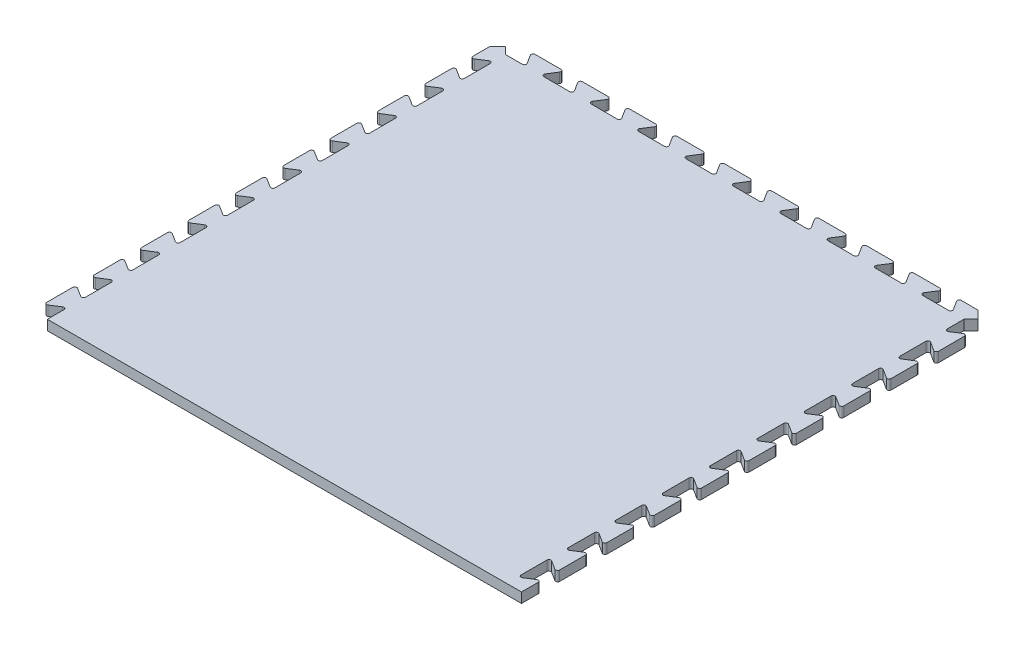
from build123d import *

# Parameters (mm, degrees)
BOSS_EXTRUDE1_DEPTH = 12.7


with BuildPart() as part:
    # Sketch1 → Boss-Extrude1 (new body)
    with BuildSketch(Plane.XZ):
        with BuildLine():
            Line((310.941368192, 290.73579192), (-291.891368192, 291.891368192))
            Line((-291.891368192, 291.891368192), (-291.891368192, 270.60420808))
            ThreePointArc((-291.891368192, 270.60420808), (-293.208312471, 268.378060129), (-295.793521501, 268.460347459))
            Line((-295.793521501, 268.460347459), (-307.039214883, 275.605568702))
            ThreePointArc((-307.039214883, 275.605568702), (-309.624423913, 275.687856032), (-310.941368192, 273.46170808))
            Line((-310.941368192, 273.46170808), (-310.941368192, 240.44170808))
            ThreePointArc((-310.941368192, 240.44170808), (-309.624423913, 238.215560129), (-307.039214883, 238.297847459))
            Line((-307.039214883, 238.297847459), (-295.793521501, 245.443068702))
            ThreePointArc((-295.793521501, 245.443068702), (-293.208312471, 245.525356032), (-291.891368192, 243.29920808))
            Line((-291.891368192, 243.29920808), (-291.891368192, 210.27920808))
            ThreePointArc((-291.891368192, 210.27920808), (-293.208312471, 208.053060129), (-295.793521501, 208.135347459))
            Line((-295.793521501, 208.135347459), (-307.039214883, 215.280568702))
            ThreePointArc((-307.039214883, 215.280568702), (-309.624423913, 215.362856032), (-310.941368192, 213.13670808))
            Line((-310.941368192, 213.13670808), (-310.941368192, 180.11670808))
            ThreePointArc((-310.941368192, 180.11670808), (-309.624423913, 177.890560129), (-307.039214883, 177.972847459))
            Line((-307.039214883, 177.972847459), (-295.793521501, 185.118068702))
            ThreePointArc((-295.793521501, 185.118068702), (-293.208312471, 185.200356032), (-291.891368192, 182.97420808))
            Line((-291.891368192, 182.97420808), (-291.891368192, 149.95420808))
            ThreePointArc((-291.891368192, 149.95420808), (-293.208312471, 147.728060129), (-295.793521501, 147.810347459))
            Line((-295.793521501, 147.810347459), (-307.039214883, 154.955568702))
            ThreePointArc((-307.039214883, 154.955568702), (-309.624423913, 155.037856032), (-310.941368192, 152.81170808))
            Line((-310.941368192, 152.81170808), (-310.941368192, 119.79170808))
            ThreePointArc((-310.941368192, 119.79170808), (-309.624423913, 117.565560129), (-307.039214883, 117.647847459))
            Line((-307.039214883, 117.647847459), (-295.793521501, 124.793068702))
            ThreePointArc((-295.793521501, 124.793068702), (-293.208312471, 124.875356032), (-291.891368192, 122.64920808))
            Line((-291.891368192, 122.64920808), (-291.891368192, 89.62920808))
            ThreePointArc((-291.891368192, 89.62920808), (-293.208312471, 87.403060129), (-295.793521501, 87.485347459))
            Line((-295.793521501, 87.485347459), (-307.039214883, 94.630568702))
            ThreePointArc((-307.039214883, 94.630568702), (-309.624423913, 94.712856032), (-310.941368192, 92.48670808))
            Line((-310.941368192, 92.48670808), (-310.941368192, 59.46670808))
            ThreePointArc((-310.941368192, 59.46670808), (-309.624423913, 57.240560129), (-307.039214883, 57.322847459))
            Line((-307.039214883, 57.322847459), (-295.793521501, 64.468068702))
            ThreePointArc((-295.793521501, 64.468068702), (-293.208312471, 64.550356032), (-291.891368192, 62.32420808))
            Line((-291.891368192, 62.32420808), (-291.891368192, 29.30420808))
            ThreePointArc((-291.891368192, 29.30420808), (-293.208312471, 27.078060129), (-295.793521501, 27.160347459))
            Line((-295.793521501, 27.160347459), (-307.039214883, 34.305568702))
            ThreePointArc((-307.039214883, 34.305568702), (-309.624423913, 34.387856032), (-310.941368192, 32.16170808))
            Line((-310.941368192, 32.16170808), (-310.941368192, -0.85829192))
            ThreePointArc((-310.941368192, -0.85829192), (-309.624423913, -3.084439871), (-307.039214883, -3.002152541))
            Line((-307.039214883, -3.002152541), (-295.793521501, 4.143068702))
            ThreePointArc((-295.793521501, 4.143068702), (-293.208312471, 4.225356032), (-291.891368192, 1.99920808))
            Line((-291.891368192, 1.99920808), (-291.891368192, -31.02079192))
            ThreePointArc((-291.891368192, -31.02079192), (-293.208312471, -33.246939871), (-295.793521501, -33.164652541))
            Line((-295.793521501, -33.164652541), (-307.039214883, -26.019431298))
            ThreePointArc((-307.039214883, -26.019431298), (-309.624423913, -25.937143968), (-310.941368192, -28.16329192))
            Line((-310.941368192, -28.16329192), (-310.941368192, -61.18329192))
            ThreePointArc((-310.941368192, -61.18329192), (-309.624423913, -63.409439871), (-307.039214883, -63.327152541))
            Line((-307.039214883, -63.327152541), (-295.793521501, -56.181931298))
            ThreePointArc((-295.793521501, -56.181931298), (-293.208312471, -56.099643968), (-291.891368192, -58.32579192))
            Line((-291.891368192, -58.32579192), (-291.891368192, -91.34579192))
            ThreePointArc((-291.891368192, -91.34579192), (-293.208312471, -93.571939871), (-295.793521501, -93.489652541))
            Line((-295.793521501, -93.489652541), (-307.039214883, -86.344431298))
            ThreePointArc((-307.039214883, -86.344431298), (-309.624423913, -86.262143968), (-310.941368192, -88.48829192))
            Line((-310.941368192, -88.48829192), (-310.941368192, -121.50829192))
            ThreePointArc((-310.941368192, -121.50829192), (-309.624423913, -123.734439871), (-307.039214883, -123.652152541))
            Line((-307.039214883, -123.652152541), (-295.793521501, -116.506931298))
            ThreePointArc((-295.793521501, -116.506931298), (-293.208312471, -116.424643968), (-291.891368192, -118.65079192))
            Line((-291.891368192, -118.65079192), (-291.891368192, -151.67079192))
            ThreePointArc((-291.891368192, -151.67079192), (-293.208312471, -153.896939871), (-295.793521501, -153.814652541))
            Line((-295.793521501, -153.814652541), (-307.039214883, -146.669431298))
            ThreePointArc((-307.039214883, -146.669431298), (-309.624423913, -146.587143968), (-310.941368192, -148.81329192))
            Line((-310.941368192, -148.81329192), (-310.941368192, -181.83329192))
            ThreePointArc((-310.941368192, -181.83329192), (-309.624423913, -184.059439871), (-307.039214883, -183.977152541))
            Line((-307.039214883, -183.977152541), (-295.793521501, -176.831931298))
            ThreePointArc((-295.793521501, -176.831931298), (-293.208312471, -176.749643968), (-291.891368192, -178.97579192))
            Line((-291.891368192, -178.97579192), (-291.891368192, -211.99579192))
            ThreePointArc((-291.891368192, -211.99579192), (-293.208312471, -214.221939871), (-295.793521501, -214.139652541))
            Line((-295.793521501, -214.139652541), (-307.039214883, -206.994431298))
            ThreePointArc((-307.039214883, -206.994431298), (-309.624423913, -206.912143968), (-310.941368192, -209.13829192))
            Line((-310.941368192, -209.13829192), (-310.941368192, -242.15829192))
            ThreePointArc((-310.941368192, -242.15829192), (-309.624423913, -244.384439871), (-307.039214883, -244.302152541))
            Line((-307.039214883, -244.302152541), (-295.793521501, -237.156931298))
            ThreePointArc((-295.793521501, -237.156931298), (-293.208312471, -237.074643968), (-291.891368192, -239.30079192))
            Line((-291.891368192, -239.30079192), (-291.891368192, -272.32079192))
            ThreePointArc((-291.891368192, -272.32079192), (-293.208312471, -274.546939871), (-295.793521501, -274.464652541))
            Line((-295.793521501, -274.464652541), (-307.039214883, -267.319431298))
            ThreePointArc((-307.039214883, -267.319431298), (-309.624423913, -267.237143968), (-310.941368192, -269.46329192))
            Line((-310.941368192, -269.46329192), (-310.941368192, -290.73579192))
            Line((-310.941368192, -290.73579192), (-300.838580056, -300.838580056))
            Line((-300.838580056, -300.838580056), (-291.891368192, -291.891368192))
            Line((-291.891368192, -291.891368192), (-270.60420808, -291.891368192))
            ThreePointArc((-270.60420808, -291.891368192), (-268.378060129, -293.208312471), (-268.460347459, -295.793521501))
            Line((-268.460347459, -295.793521501), (-275.605568702, -307.039214883))
            ThreePointArc((-275.605568702, -307.039214883), (-275.687856032, -309.624423913), (-273.46170808, -310.941368192))
            Line((-273.46170808, -310.941368192), (-240.44170808, -310.941368192))
            ThreePointArc((-240.44170808, -310.941368192), (-238.215560129, -309.624423913), (-238.297847459, -307.039214883))
            Line((-238.297847459, -307.039214883), (-245.443068702, -295.793521501))
            ThreePointArc((-245.443068702, -295.793521501), (-245.525356032, -293.208312471), (-243.29920808, -291.891368192))
            Line((-243.29920808, -291.891368192), (-210.27920808, -291.891368192))
            ThreePointArc((-210.27920808, -291.891368192), (-208.053060129, -293.208312471), (-208.135347459, -295.793521501))
            Line((-208.135347459, -295.793521501), (-215.280568702, -307.039214883))
            ThreePointArc((-215.280568702, -307.039214883), (-215.362856032, -309.624423913), (-213.13670808, -310.941368192))
            Line((-213.13670808, -310.941368192), (-180.11670808, -310.941368192))
            ThreePointArc((-180.11670808, -310.941368192), (-177.890560129, -309.624423913), (-177.972847459, -307.039214883))
            Line((-177.972847459, -307.039214883), (-185.118068702, -295.793521501))
            ThreePointArc((-185.118068702, -295.793521501), (-185.200356032, -293.208312471), (-182.97420808, -291.891368192))
            Line((-182.97420808, -291.891368192), (-149.95420808, -291.891368192))
            ThreePointArc((-149.95420808, -291.891368192), (-147.728060129, -293.208312471), (-147.810347459, -295.793521501))
            Line((-147.810347459, -295.793521501), (-154.955568702, -307.039214883))
            ThreePointArc((-154.955568702, -307.039214883), (-155.037856032, -309.624423913), (-152.81170808, -310.941368192))
            Line((-152.81170808, -310.941368192), (-119.79170808, -310.941368192))
            ThreePointArc((-119.79170808, -310.941368192), (-117.565560129, -309.624423913), (-117.647847459, -307.039214883))
            Line((-117.647847459, -307.039214883), (-124.793068702, -295.793521501))
            ThreePointArc((-124.793068702, -295.793521501), (-124.875356032, -293.208312471), (-122.64920808, -291.891368192))
            Line((-122.64920808, -291.891368192), (-89.62920808, -291.891368192))
            ThreePointArc((-89.62920808, -291.891368192), (-87.403060129, -293.208312471), (-87.485347459, -295.793521501))
            Line((-87.485347459, -295.793521501), (-94.630568702, -307.039214883))
            ThreePointArc((-94.630568702, -307.039214883), (-94.712856032, -309.624423913), (-92.48670808, -310.941368192))
            Line((-92.48670808, -310.941368192), (-59.46670808, -310.941368192))
            ThreePointArc((-59.46670808, -310.941368192), (-57.240560129, -309.624423913), (-57.322847459, -307.039214883))
            Line((-57.322847459, -307.039214883), (-64.468068702, -295.793521501))
            ThreePointArc((-64.468068702, -295.793521501), (-64.550356032, -293.208312471), (-62.32420808, -291.891368192))
            Line((-62.32420808, -291.891368192), (-29.30420808, -291.891368192))
            ThreePointArc((-29.30420808, -291.891368192), (-27.078060129, -293.208312471), (-27.160347459, -295.793521501))
            Line((-27.160347459, -295.793521501), (-34.305568702, -307.039214883))
            ThreePointArc((-34.305568702, -307.039214883), (-34.387856032, -309.624423913), (-32.16170808, -310.941368192))
            Line((-32.16170808, -310.941368192), (0.85829192, -310.941368192))
            ThreePointArc((0.85829192, -310.941368192), (3.084439871, -309.624423913), (3.002152541, -307.039214883))
            Line((3.002152541, -307.039214883), (-4.143068702, -295.793521501))
            ThreePointArc((-4.143068702, -295.793521501), (-4.225356032, -293.208312471), (-1.99920808, -291.891368192))
            Line((-1.99920808, -291.891368192), (31.02079192, -291.891368192))
            ThreePointArc((31.02079192, -291.891368192), (33.246939871, -293.208312471), (33.164652541, -295.793521501))
            Line((33.164652541, -295.793521501), (26.019431298, -307.039214883))
            ThreePointArc((26.019431298, -307.039214883), (25.937143968, -309.624423913), (28.16329192, -310.941368192))
            Line((28.16329192, -310.941368192), (61.18329192, -310.941368192))
            ThreePointArc((61.18329192, -310.941368192), (63.409439871, -309.624423913), (63.327152541, -307.039214883))
            Line((63.327152541, -307.039214883), (56.181931298, -295.793521501))
            ThreePointArc((56.181931298, -295.793521501), (56.099643968, -293.208312471), (58.32579192, -291.891368192))
            Line((58.32579192, -291.891368192), (91.34579192, -291.891368192))
            ThreePointArc((91.34579192, -291.891368192), (93.571939871, -293.208312471), (93.489652541, -295.793521501))
            Line((93.489652541, -295.793521501), (86.344431298, -307.039214883))
            ThreePointArc((86.344431298, -307.039214883), (86.262143968, -309.624423913), (88.48829192, -310.941368192))
            Line((88.48829192, -310.941368192), (121.50829192, -310.941368192))
            ThreePointArc((121.50829192, -310.941368192), (123.734439871, -309.624423913), (123.652152541, -307.039214883))
            Line((123.652152541, -307.039214883), (116.506931298, -295.793521501))
            ThreePointArc((116.506931298, -295.793521501), (116.424643968, -293.208312471), (118.65079192, -291.891368192))
            Line((118.65079192, -291.891368192), (151.67079192, -291.891368192))
            ThreePointArc((151.67079192, -291.891368192), (153.896939871, -293.208312471), (153.814652541, -295.793521501))
            Line((153.814652541, -295.793521501), (146.669431298, -307.039214883))
            ThreePointArc((146.669431298, -307.039214883), (146.587143968, -309.624423913), (148.81329192, -310.941368192))
            Line((148.81329192, -310.941368192), (181.83329192, -310.941368192))
            ThreePointArc((181.83329192, -310.941368192), (184.059439871, -309.624423913), (183.977152541, -307.039214883))
            Line((183.977152541, -307.039214883), (176.831931298, -295.793521501))
            ThreePointArc((176.831931298, -295.793521501), (176.749643968, -293.208312471), (178.97579192, -291.891368192))
            Line((178.97579192, -291.891368192), (211.99579192, -291.891368192))
            ThreePointArc((211.99579192, -291.891368192), (214.221939871, -293.208312471), (214.139652541, -295.793521501))
            Line((214.139652541, -295.793521501), (206.994431298, -307.039214883))
            ThreePointArc((206.994431298, -307.039214883), (206.912143968, -309.624423913), (209.13829192, -310.941368192))
            Line((209.13829192, -310.941368192), (242.15829192, -310.941368192))
            ThreePointArc((242.15829192, -310.941368192), (244.384439871, -309.624423913), (244.302152541, -307.039214883))
            Line((244.302152541, -307.039214883), (237.156931298, -295.793521501))
            ThreePointArc((237.156931298, -295.793521501), (237.074643968, -293.208312471), (239.30079192, -291.891368192))
            Line((239.30079192, -291.891368192), (272.32079192, -291.891368192))
            ThreePointArc((272.32079192, -291.891368192), (274.546939871, -293.208312471), (274.464652541, -295.793521501))
            Line((274.464652541, -295.793521501), (267.319431298, -307.039214883))
            ThreePointArc((267.319431298, -307.039214883), (267.237143968, -309.624423913), (269.46329192, -310.941368192))
            Line((269.46329192, -310.941368192), (290.73579192, -310.941368192))
            Line((290.73579192, -310.941368192), (300.838580056, -300.838580056))
            Line((300.838580056, -300.838580056), (291.891368192, -291.891368192))
            Line((291.891368192, -291.891368192), (291.891368192, -270.60420808))
            ThreePointArc((291.891368192, -270.60420808), (293.208312471, -268.378060129), (295.793521501, -268.460347459))
            Line((295.793521501, -268.460347459), (307.039214883, -275.605568702))
            ThreePointArc((307.039214883, -275.605568702), (309.624423913, -275.687856032), (310.941368192, -273.46170808))
            Line((310.941368192, -273.46170808), (310.941368192, -240.44170808))
            ThreePointArc((310.941368192, -240.44170808), (309.624423913, -238.215560129), (307.039214883, -238.297847459))
            Line((307.039214883, -238.297847459), (295.793521501, -245.443068702))
            ThreePointArc((295.793521501, -245.443068702), (293.208312471, -245.525356032), (291.891368192, -243.29920808))
            Line((291.891368192, -243.29920808), (291.891368192, -210.27920808))
            ThreePointArc((291.891368192, -210.27920808), (293.208312471, -208.053060129), (295.793521501, -208.135347459))
            Line((295.793521501, -208.135347459), (307.039214883, -215.280568702))
            ThreePointArc((307.039214883, -215.280568702), (309.624423913, -215.362856032), (310.941368192, -213.13670808))
            Line((310.941368192, -213.13670808), (310.941368192, -180.11670808))
            ThreePointArc((310.941368192, -180.11670808), (309.624423913, -177.890560129), (307.039214883, -177.972847459))
            Line((307.039214883, -177.972847459), (295.793521501, -185.118068702))
            ThreePointArc((295.793521501, -185.118068702), (293.208312471, -185.200356032), (291.891368192, -182.97420808))
            Line((291.891368192, -182.97420808), (291.891368192, -149.95420808))
            ThreePointArc((291.891368192, -149.95420808), (293.208312471, -147.728060129), (295.793521501, -147.810347459))
            Line((295.793521501, -147.810347459), (307.039214883, -154.955568702))
            ThreePointArc((307.039214883, -154.955568702), (309.624423913, -155.037856032), (310.941368192, -152.81170808))
            Line((310.941368192, -152.81170808), (310.941368192, -119.79170808))
            ThreePointArc((310.941368192, -119.79170808), (309.624423913, -117.565560129), (307.039214883, -117.647847459))
            Line((307.039214883, -117.647847459), (295.793521501, -124.793068702))
            ThreePointArc((295.793521501, -124.793068702), (293.208312471, -124.875356032), (291.891368192, -122.64920808))
            Line((291.891368192, -122.64920808), (291.891368192, -89.62920808))
            ThreePointArc((291.891368192, -89.62920808), (293.208312471, -87.403060129), (295.793521501, -87.485347459))
            Line((295.793521501, -87.485347459), (307.039214883, -94.630568702))
            ThreePointArc((307.039214883, -94.630568702), (309.624423913, -94.712856032), (310.941368192, -92.48670808))
            Line((310.941368192, -92.48670808), (310.941368192, -59.46670808))
            ThreePointArc((310.941368192, -59.46670808), (309.624423913, -57.240560129), (307.039214883, -57.322847459))
            Line((307.039214883, -57.322847459), (295.793521501, -64.468068702))
            ThreePointArc((295.793521501, -64.468068702), (293.208312471, -64.550356032), (291.891368192, -62.32420808))
            Line((291.891368192, -62.32420808), (291.891368192, -29.30420808))
            ThreePointArc((291.891368192, -29.30420808), (293.208312471, -27.078060129), (295.793521501, -27.160347459))
            Line((295.793521501, -27.160347459), (307.039214883, -34.305568702))
            ThreePointArc((307.039214883, -34.305568702), (309.624423913, -34.387856032), (310.941368192, -32.16170808))
            Line((310.941368192, -32.16170808), (310.941368192, 0.85829192))
            ThreePointArc((310.941368192, 0.85829192), (309.624423913, 3.084439871), (307.039214883, 3.002152541))
            Line((307.039214883, 3.002152541), (295.793521501, -4.143068702))
            ThreePointArc((295.793521501, -4.143068702), (293.208312471, -4.225356032), (291.891368192, -1.99920808))
            Line((291.891368192, -1.99920808), (291.891368192, 31.02079192))
            ThreePointArc((291.891368192, 31.02079192), (293.208312471, 33.246939871), (295.793521501, 33.164652541))
            Line((295.793521501, 33.164652541), (307.039214883, 26.019431298))
            ThreePointArc((307.039214883, 26.019431298), (309.624423913, 25.937143968), (310.941368192, 28.16329192))
            Line((310.941368192, 28.16329192), (310.941368192, 61.18329192))
            ThreePointArc((310.941368192, 61.18329192), (309.624423913, 63.409439871), (307.039214883, 63.327152541))
            Line((307.039214883, 63.327152541), (295.793521501, 56.181931298))
            ThreePointArc((295.793521501, 56.181931298), (293.208312471, 56.099643968), (291.891368192, 58.32579192))
            Line((291.891368192, 58.32579192), (291.891368192, 91.34579192))
            ThreePointArc((291.891368192, 91.34579192), (293.208312471, 93.571939871), (295.793521501, 93.489652541))
            Line((295.793521501, 93.489652541), (307.039214883, 86.344431298))
            ThreePointArc((307.039214883, 86.344431298), (309.624423913, 86.262143968), (310.941368192, 88.48829192))
            Line((310.941368192, 88.48829192), (310.941368192, 121.50829192))
            ThreePointArc((310.941368192, 121.50829192), (309.624423913, 123.734439871), (307.039214883, 123.652152541))
            Line((307.039214883, 123.652152541), (295.793521501, 116.506931298))
            ThreePointArc((295.793521501, 116.506931298), (293.208312471, 116.424643968), (291.891368192, 118.65079192))
            Line((291.891368192, 118.65079192), (291.891368192, 151.67079192))
            ThreePointArc((291.891368192, 151.67079192), (293.208312471, 153.896939871), (295.793521501, 153.814652541))
            Line((295.793521501, 153.814652541), (307.039214883, 146.669431298))
            ThreePointArc((307.039214883, 146.669431298), (309.624423913, 146.587143968), (310.941368192, 148.81329192))
            Line((310.941368192, 148.81329192), (310.941368192, 181.83329192))
            ThreePointArc((310.941368192, 181.83329192), (309.624423913, 184.059439871), (307.039214883, 183.977152541))
            Line((307.039214883, 183.977152541), (295.793521501, 176.831931298))
            ThreePointArc((295.793521501, 176.831931298), (293.208312471, 176.749643968), (291.891368192, 178.97579192))
            Line((291.891368192, 178.97579192), (291.891368192, 211.99579192))
            ThreePointArc((291.891368192, 211.99579192), (293.208312471, 214.221939871), (295.793521501, 214.139652541))
            Line((295.793521501, 214.139652541), (307.039214883, 206.994431298))
            ThreePointArc((307.039214883, 206.994431298), (309.624423913, 206.912143968), (310.941368192, 209.13829192))
            Line((310.941368192, 209.13829192), (310.941368192, 242.15829192))
            ThreePointArc((310.941368192, 242.15829192), (309.624423913, 244.384439871), (307.039214883, 244.302152541))
            Line((307.039214883, 244.302152541), (295.793521501, 237.156931298))
            ThreePointArc((295.793521501, 237.156931298), (293.208312471, 237.074643968), (291.891368192, 239.30079192))
            Line((291.891368192, 239.30079192), (291.891368192, 272.32079192))
            ThreePointArc((291.891368192, 272.32079192), (293.208312471, 274.546939871), (295.793521501, 274.464652541))
            Line((295.793521501, 274.464652541), (307.039214883, 267.319431298))
            ThreePointArc((307.039214883, 267.319431298), (309.624423913, 267.237143968), (310.941368192, 269.46329192))
            Line((310.941368192, 269.46329192), (310.941368192, 290.73579192))
        make_face()
    extrude(amount=-BOSS_EXTRUDE1_DEPTH)


solid = part.part
